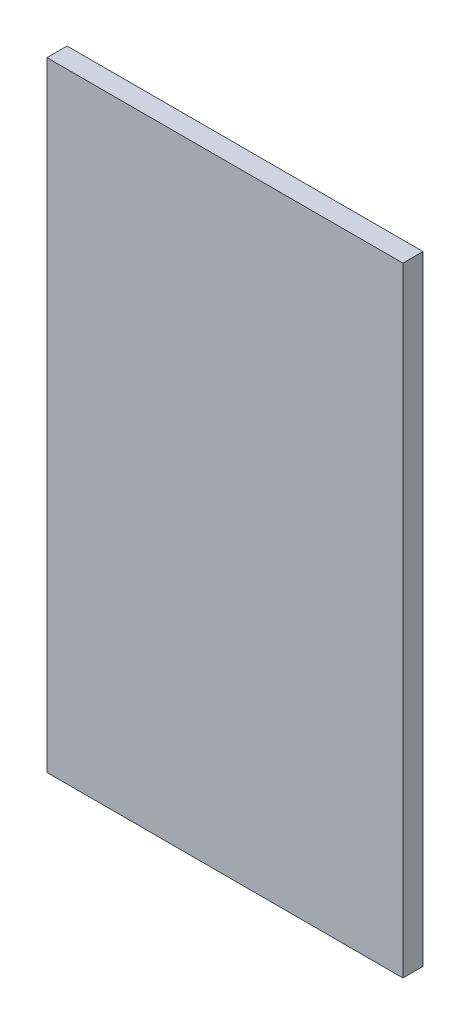
from build123d import *

# Parameters (mm, degrees)
SKETCH1_W           = 230
SKETCH1_H           = 400
BOSS_EXTRUDE1_DEPTH = 13


with BuildPart() as part:
    # Sketch1 → Boss-Extrude1 (new body)
    with BuildSketch(Plane.XY):
        Rectangle(SKETCH1_W, SKETCH1_H)
    extrude(amount=BOSS_EXTRUDE1_DEPTH)


solid = part.part
